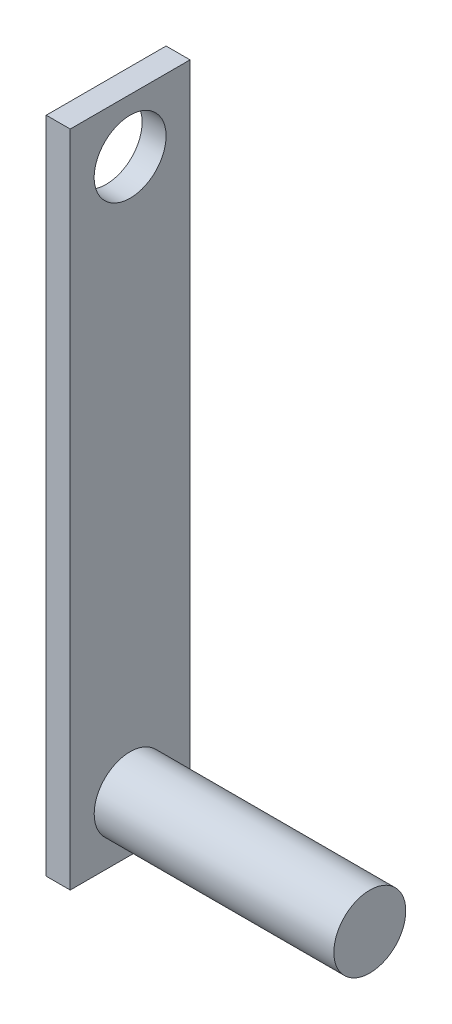
from build123d import *

# Parameters (mm, degrees)
SKETCH1_W           = 10
SKETCH1_H           = 55
BOSS_EXTRUDE1_DEPTH = 2
SKETCH2_R           = 3
CUT_EXTRUDE1_DEPTH  = 2
SKETCH3_R           = 3
BOSS_EXTRUDE2_DEPTH = 20


with BuildPart() as part:
    # Sketch1 → Boss-Extrude1 (new body)
    with BuildSketch(Plane(origin=(0, 0, 0), x_dir=(0, 0, -1), z_dir=(1, 0, 0))):
        Rectangle(SKETCH1_W, SKETCH1_H)
    extrude(amount=BOSS_EXTRUDE1_DEPTH)

    # Sketch2 → Cut-Extrude1 (cut)
    with BuildSketch(Plane(origin=(2, 0, 0), x_dir=(0, 0, -1), z_dir=(1, 0, 0))):
        with Locations((0, 23)):
            Circle(SKETCH2_R)
    extrude(amount=-CUT_EXTRUDE1_DEPTH, mode=Mode.SUBTRACT)

    # Sketch3 → Boss-Extrude2 (add)
    with BuildSketch(Plane(origin=(2, 0, 0), x_dir=(0, 0, -1), z_dir=(1, 0, 0))):
        with Locations((0, -23)):
            Circle(SKETCH3_R)
    extrude(amount=BOSS_EXTRUDE2_DEPTH)


solid = part.part
